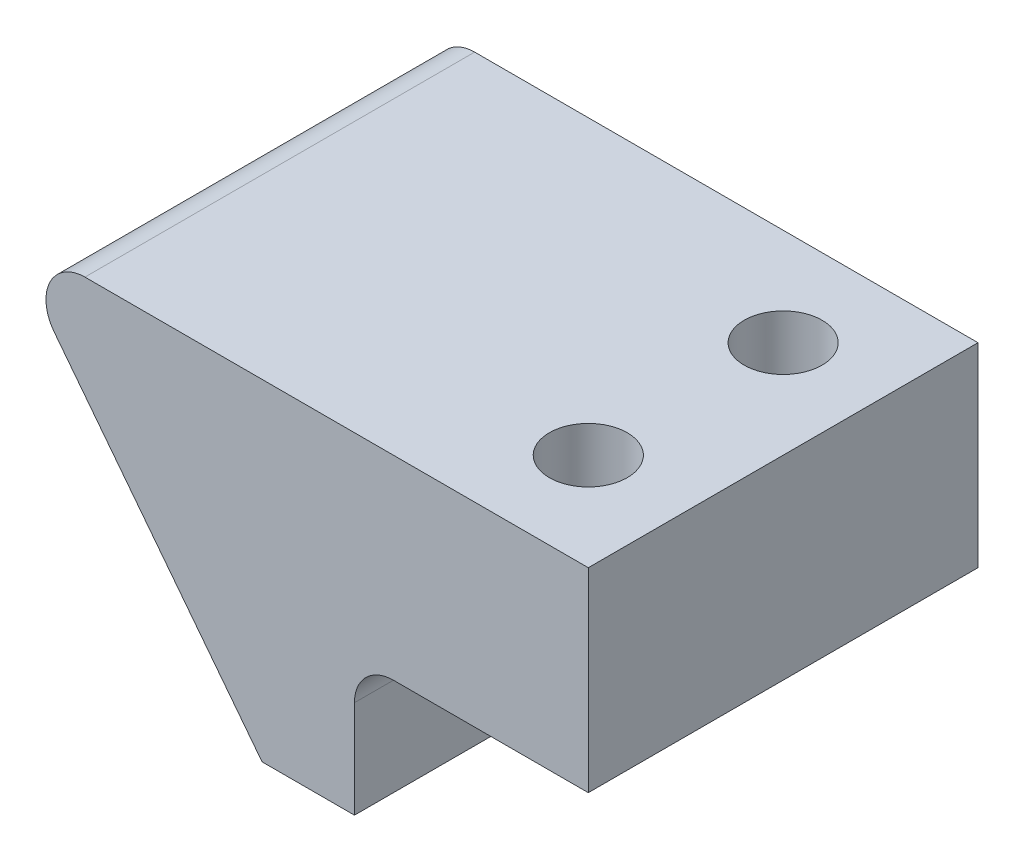
from build123d import *

# Parameters (mm, degrees)
EXTRUDE_1_DEPTH      = 5
EXTRUDE_1_DEPTH_BACK = 5
FILLET_1_R           = 1
MM_CLEARANCE_1_D     = 2


with BuildPart() as part:
    # 草图2 → 凸台-拉伸1 (new, two sides: drawn at the far end of the back side and taken through both)
    with BuildSketch(Plane.XY.offset(-EXTRUDE_1_DEPTH_BACK)):
        Polygon((15.044070129, 19), (30, 19), (30, 14), (24, 14), (24, 10.5), (21.629319922, 10.5), align=None)
    extrude(amount=EXTRUDE_1_DEPTH + EXTRUDE_1_DEPTH_BACK)

    # 圆角1
    fillet_1_edges = [part.edges().sort_by_distance(p)[0] for p in [
        (24, 14, 0),
        (15.044070129, 19, 0),
    ]]
    fillet(fillet_1_edges, radius=FILLET_1_R)

    # 大小mm Clearance 暗销孔1 (through all)
    with Locations(Plane(origin=(0, 14, 0), x_dir=(-1, 0, 0), z_dir=(0, -1, 0))):
        with Locations((-27.5, 2.499999967), (-27.5, -2.500000033)):
            Hole(MM_CLEARANCE_1_D / 2)


solid = part.part
